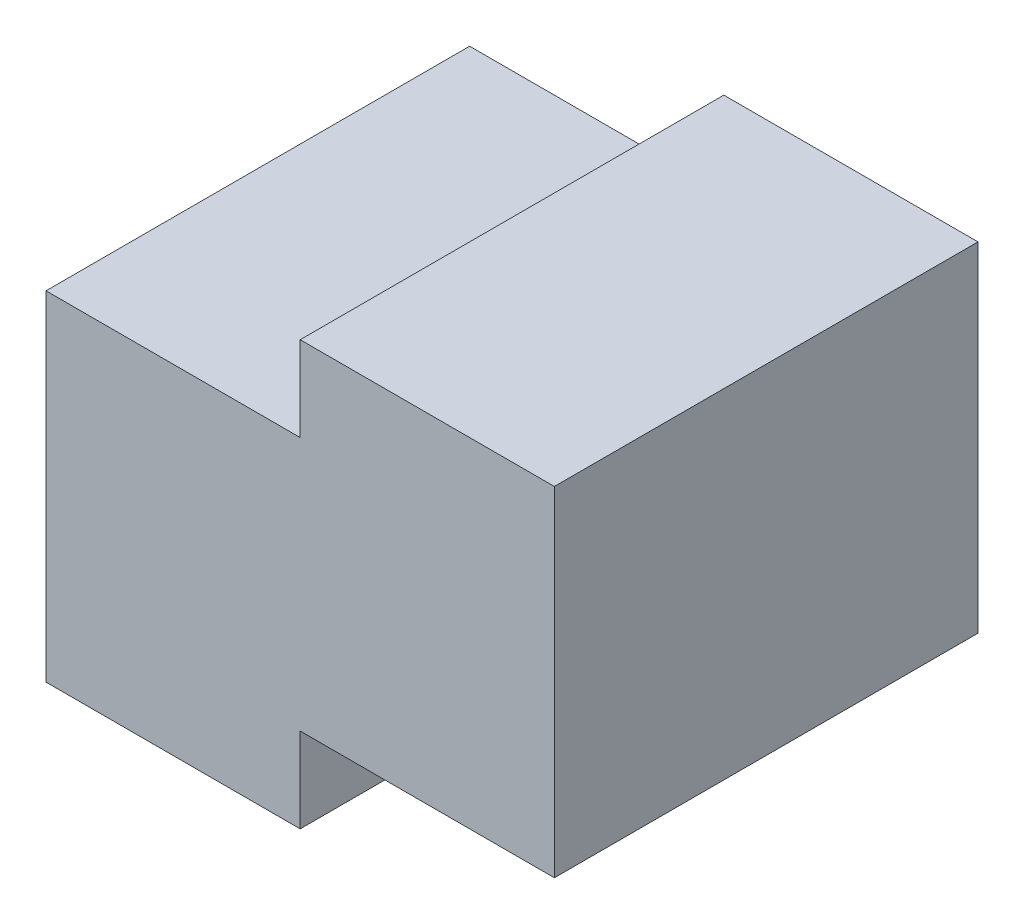
from build123d import *

# Parameters (mm, degrees)
BOSS_EXTRUDE1_DEPTH = 25


with BuildPart() as part:
    # Sketch1 → Boss-Extrude1 (new body)
    with BuildSketch(Plane.XY):
        Polygon((-30, 15), (-15, 15), (-15, 20), (0, 20), (0, 0), (-15, 0), (-15, -5), (-30, -5), align=None)
    extrude(amount=BOSS_EXTRUDE1_DEPTH)


solid = part.part
